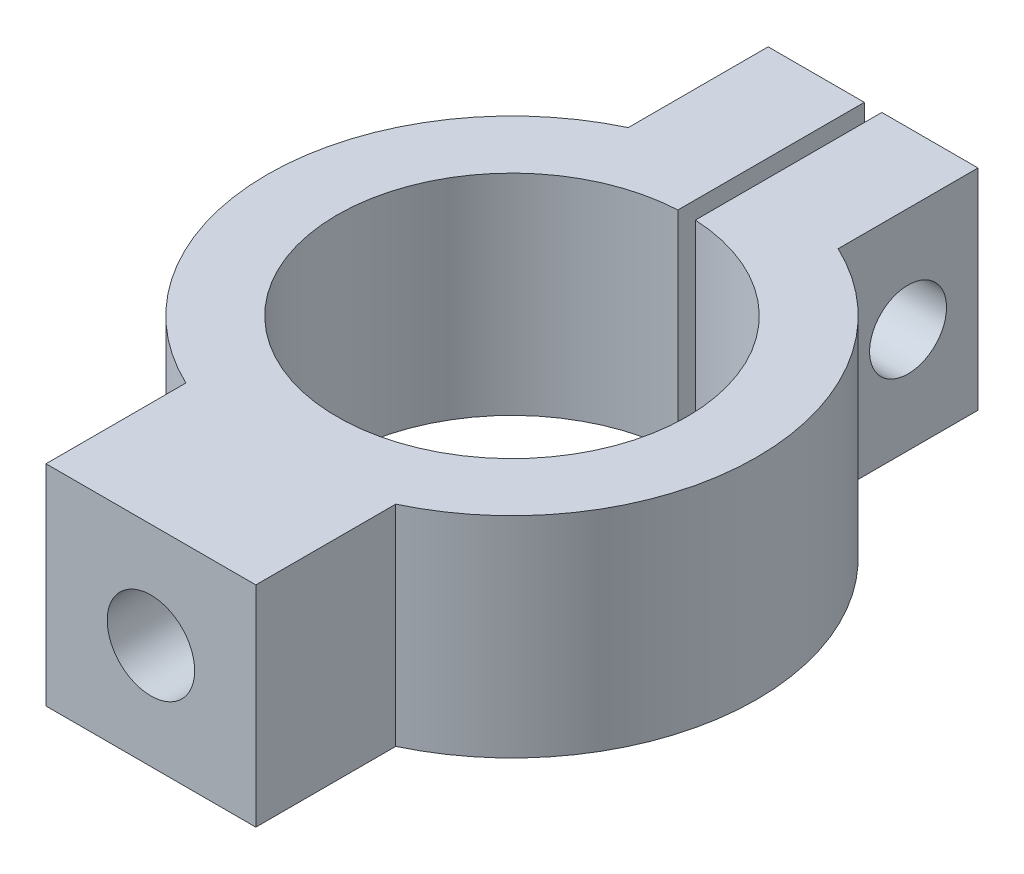
from build123d import *

# Parameters (mm, degrees)
LOOP_SKETCH_R                   = 7
LOOP_SKETCH_R_2                 = 5
LOOP_EXTRUDE_DEPTH              = 6
BLOCK_SKETCH_W                  = 6
BLOCK_SKETCH_H                  = 4
BLOCK_EXTRUDE_DEPTH             = 6
SLOT_SKETCH_W                   = 0.5
SLOT_SKETCH_H                   = 5.330809231
SLOT_CUT_DEPTH                  = 6
M3X0_5_TAPPED_HOLE1_D           = 2.5
M3X0_5_TAPPED_HOLE1_DEPTH       = 4
M3X0_5_TAPPED_HOLE1_TIP         = 0.751075774
F_2_2_2_2_DIAMETER_HOLE1_REACH  = 17.576
F_2_2_2_2_DIAMETER_HOLE1_BORE_R = 1.1
M2X0_4_TAPPED_HOLE1_D           = 1.6


with BuildPart() as part:
    # Loop Sketch → Loop Extrude (new body)
    with BuildSketch(Plane(origin=(0, 0, 0), x_dir=(1, 0, 0), z_dir=(0, 1, 0))):
        with Locations(Location((0, 0, 0), (0, 0, 270))):
            Circle(LOOP_SKETCH_R)
        with Locations(Location((0, 0, 0), (0, 0, 270))):
            Circle(LOOP_SKETCH_R_2, mode=Mode.SUBTRACT)
    extrude(amount=LOOP_EXTRUDE_DEPTH)

    # Block Sketch → Block Extrude (add)
    with BuildSketch(Plane(origin=(0, 0, 0), x_dir=(1, 0, 0), z_dir=(0, 1, 0))):
        with Locations((0, -8.32455532)):
            Rectangle(BLOCK_SKETCH_W, BLOCK_SKETCH_H)
        with Locations((0, 8.32455532)):
            Rectangle(BLOCK_SKETCH_W, BLOCK_SKETCH_H)
    extrude(amount=BLOCK_EXTRUDE_DEPTH)

    # Slot Sketch → Slot Cut (cut)
    with BuildSketch(Plane(origin=(0, 0, 0), x_dir=(1, 0, 0), z_dir=(0, 1, 0))):
        with Locations((0, 7.659150705)):
            Rectangle(SLOT_SKETCH_W, SLOT_SKETCH_H)
    extrude(amount=SLOT_CUT_DEPTH, mode=Mode.SUBTRACT)

    # M3x0.5 Tapped Hole1
    with Locations(Plane.XY.offset(10.32455532)):
        with Locations((0, 3)):
            Hole(M3X0_5_TAPPED_HOLE1_D / 2, depth=M3X0_5_TAPPED_HOLE1_DEPTH)
            with Locations((0, 0, -(M3X0_5_TAPPED_HOLE1_DEPTH + M3X0_5_TAPPED_HOLE1_TIP / 2))):  # 118° drill point
                Cone(0, M3X0_5_TAPPED_HOLE1_D / 2, M3X0_5_TAPPED_HOLE1_TIP, mode=Mode.SUBTRACT)

    # Ø2.2 (2.2) Diameter Hole1 bore → Ø2.2 (2.2) Diameter Hole1 (cut, up to next)
    with BuildSketch(Plane(origin=(3, 0, 0), x_dir=(0, 0, -1), z_dir=(1, 0, 0)), mode=Mode.PRIVATE) as f_2_2_2_2_diameter_hole1_sk1:
        with Locations((8.32455532, 3)):
            Circle(F_2_2_2_2_DIAMETER_HOLE1_BORE_R)
    f_2_2_2_2_diameter_hole1_tool1 = extrude(f_2_2_2_2_diameter_hole1_sk1.sketch, amount=-F_2_2_2_2_DIAMETER_HOLE1_REACH, mode=Mode.PRIVATE) & part.part
    add(f_2_2_2_2_diameter_hole1_tool1.solids().sort_by_distance((3, 3, -8.324555))[0], mode=Mode.SUBTRACT)

    # M2x0.4 Tapped Hole1 (through all)
    with Locations(Plane(origin=(-0.25, 0, 0), x_dir=(0, 0, -1), z_dir=(1, 0, 0))):
        with Locations((8.32455532, 3)):
            Hole(M2X0_4_TAPPED_HOLE1_D / 2)


solid = part.part
